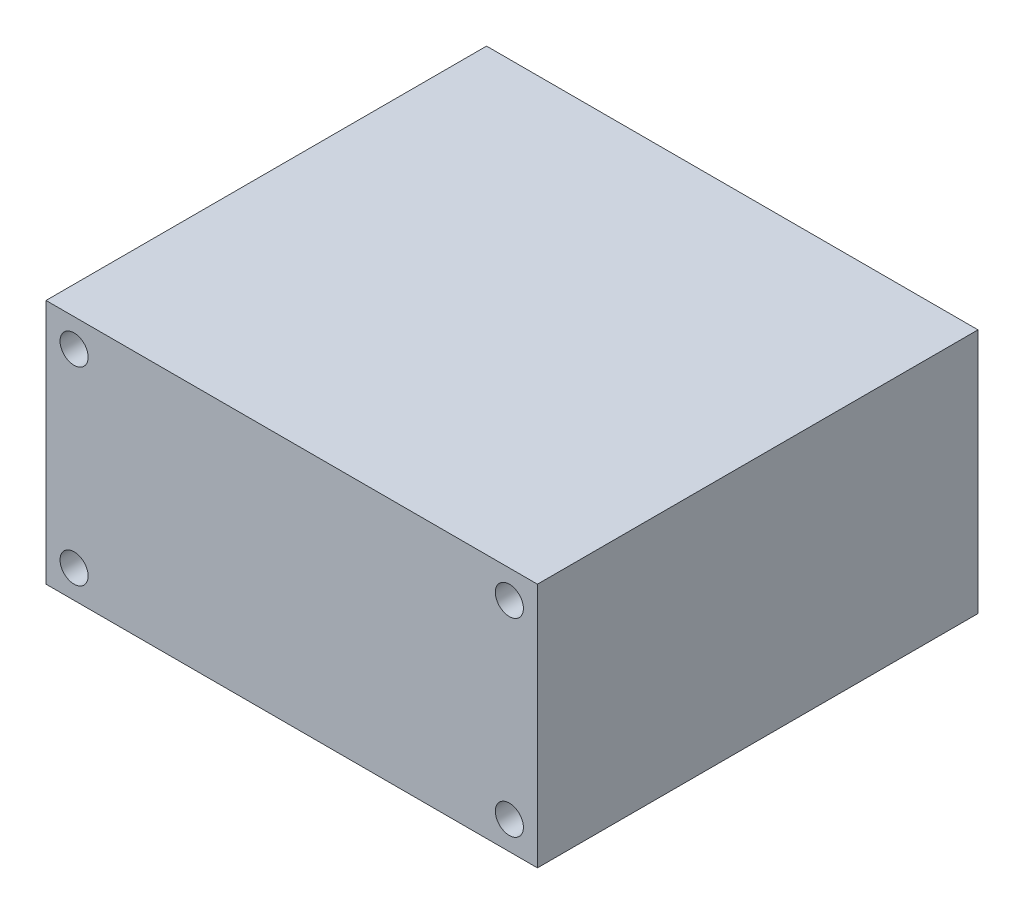
from build123d import *

# Parameters (mm, degrees)
SKETCH_2_W          = 56
SKETCH_2_H          = 28
EXTRUDE_1_DEPTH     = 50.2
SKETCH_4_R          = 1.6
CUT_EXTRUDE_1_DEPTH = 50.2


with BuildPart() as part:
    # 草图2 → 凸台-拉伸1 (new body)
    with BuildSketch(Plane.XY):
        with Locations((-28, 14)):
            Rectangle(SKETCH_2_W, SKETCH_2_H)
    extrude(amount=EXTRUDE_1_DEPTH)

    # 草图4 → 切除-拉伸1 (cut)
    with BuildSketch(Plane.XY.offset(50.2)):
        with Locations((-52.8, 24.8)):
            Circle(SKETCH_4_R)
        with Locations((-3.2, 3.2)):
            Circle(SKETCH_4_R)
        with Locations((-52.8, 3.2)):
            Circle(SKETCH_4_R)
        with Locations((-3.2, 24.8)):
            Circle(SKETCH_4_R)
    extrude(amount=-CUT_EXTRUDE_1_DEPTH, mode=Mode.SUBTRACT)


solid = part.part
